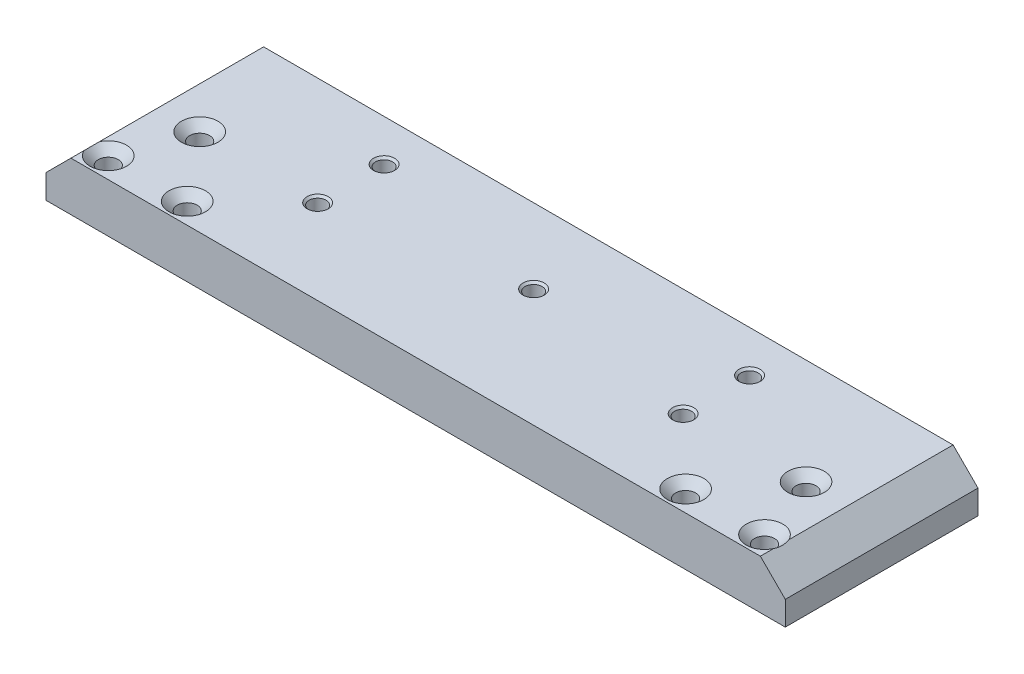
from build123d import *

# Parameters (mm, degrees)
SKETCH1_W                                       = 89
SKETCH1_H                                       = 23.2
BOSS_EXTRUDE1_DEPTH                             = 4
BOSS_EXTRUDE1_DEPTH_BACK                        = 1.9
M2_5X0_45_TAPPED_HOLE2_D                        = 2.05
M2_5X0_45_TAPPED_HOLE2_CSINK_D                  = 2.55
M2_5X0_45_TAPPED_HOLE2_CSINK_ANGLE              = 90
CSK_FOR_M2_FLAT_HEAD_MACHINE_SCREW1_D           = 2.4
CSK_FOR_M2_FLAT_HEAD_MACHINE_SCREW1_DEPTH       = 6.45
CSK_FOR_M2_FLAT_HEAD_MACHINE_SCREW1_CSINK_D     = 4.4
CSK_FOR_M2_FLAT_HEAD_MACHINE_SCREW1_CSINK_ANGLE = 90
CSK_FOR_M2_FLAT_HEAD_MACHINE_SCREW1_TIP         = 0.721032743
CUT_EXTRUDE1_DEPTH                              = 23.2


with BuildPart() as part:
    # Sketch1 → Boss-Extrude1 (new body, two sides)
    with BuildSketch(Plane(origin=(0, 0, 0), x_dir=(1, 0, 0), z_dir=(0, 1, 0))) as boss_extrude1_sk:
        Rectangle(SKETCH1_W, SKETCH1_H)
    extrude(amount=BOSS_EXTRUDE1_DEPTH)
    extrude(boss_extrude1_sk.sketch, amount=-BOSS_EXTRUDE1_DEPTH_BACK)

    # M2.5x0.45 Tapped Hole2 (through all)
    with Locations(Plane(origin=(0, 4, 0), x_dir=(1, 0, 0), z_dir=(0, 1, 0))):
        with Locations((-22, 6.6), (-22, -1.4), (22, -1.4), (22, 6.6), (0, 2.6)):
            CounterSinkHole(M2_5X0_45_TAPPED_HOLE2_D / 2, M2_5X0_45_TAPPED_HOLE2_CSINK_D / 2, counter_sink_angle=M2_5X0_45_TAPPED_HOLE2_CSINK_ANGLE)

    # CSK for M2 Flat Head Machine Screw1
    with Locations(Plane(origin=(0, 4, 0), x_dir=(1, 0, 0), z_dir=(0, 1, 0))):
        with Locations((-36.5, -1.1), (-39.5, -9.1), (-30, -9.1), (30, -9.1), (39.5, -9.1), (36.5, -1.1)):
            CounterSinkHole(CSK_FOR_M2_FLAT_HEAD_MACHINE_SCREW1_D / 2, CSK_FOR_M2_FLAT_HEAD_MACHINE_SCREW1_CSINK_D / 2, depth=CSK_FOR_M2_FLAT_HEAD_MACHINE_SCREW1_DEPTH, counter_sink_angle=CSK_FOR_M2_FLAT_HEAD_MACHINE_SCREW1_CSINK_ANGLE)
            with Locations((0, 0, -(CSK_FOR_M2_FLAT_HEAD_MACHINE_SCREW1_DEPTH + CSK_FOR_M2_FLAT_HEAD_MACHINE_SCREW1_TIP / 2))):  # 118° drill point
                Cone(0, CSK_FOR_M2_FLAT_HEAD_MACHINE_SCREW1_D / 2, CSK_FOR_M2_FLAT_HEAD_MACHINE_SCREW1_TIP, mode=Mode.SUBTRACT)

    # Sketch8 → Cut-Extrude1 (cut)
    with BuildSketch(Plane.XY.offset(11.6)):
        Polygon((41.5, 4), (44.5, 4), (44.5, 1), align=None)
        Polygon((-44.5, 4), (-44.5, 1), (-41.5, 4), align=None)
    extrude(amount=-CUT_EXTRUDE1_DEPTH, mode=Mode.SUBTRACT)


solid = part.part
